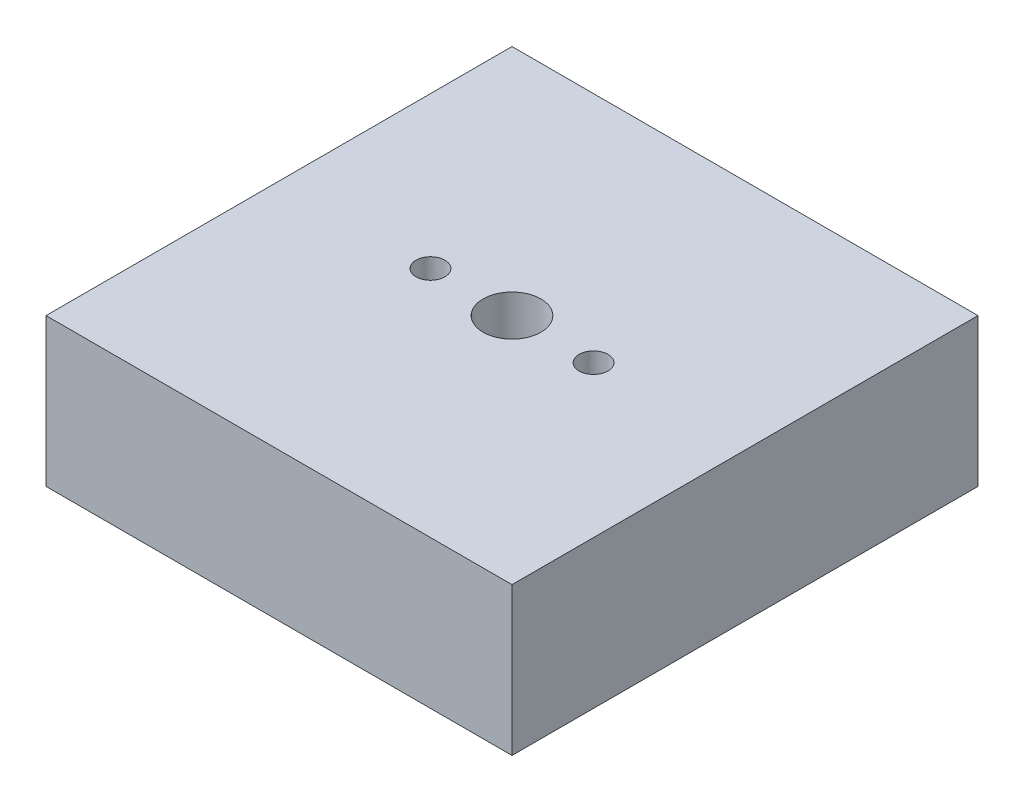
from build123d import *

# Parameters (mm, degrees)
SKETCH1_W           = 10
SKETCH1_H           = 10
SKETCH1_R           = 0.31
SKETCH1_R_2         = 0.62
BOSS_EXTRUDE1_DEPTH = 3.175


with BuildPart() as part:
    # Sketch1 → Boss-Extrude1 (new body)
    with BuildSketch(Plane(origin=(0, 0, 0), x_dir=(1, 0, 0), z_dir=(0, 1, 0))):
        Rectangle(SKETCH1_W, SKETCH1_H)
        with Locations((-1.75, 0)):
            Circle(SKETCH1_R, mode=Mode.SUBTRACT)
        Circle(SKETCH1_R_2, mode=Mode.SUBTRACT)
        with Locations((1.75, 0)):
            Circle(SKETCH1_R, mode=Mode.SUBTRACT)
    extrude(amount=BOSS_EXTRUDE1_DEPTH)


solid = part.part
